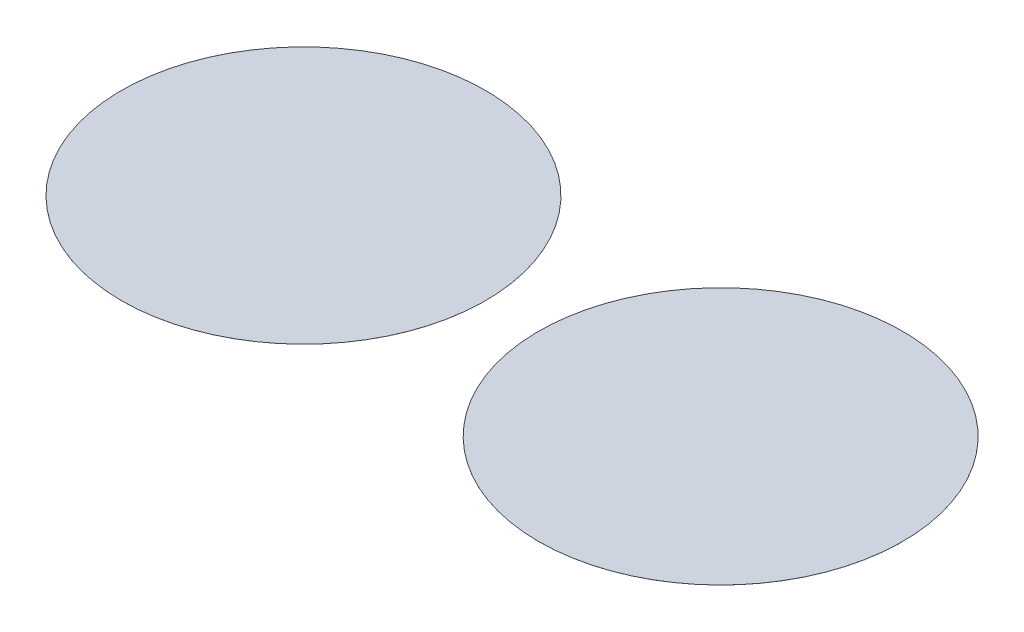
from build123d import *

# Parameters (mm, degrees)
SKETCH1_R             = 4500
BOSS_EXTRUDE1_DEPTH   = 0.5
BOSS_EXTRUDE1_2_DEPTH = 0.5


with BuildPart() as part:
    # Sketch1 → Boss-Extrude1 (new body)
    with BuildSketch(Plane(origin=(0, 0, 0), x_dir=(1, 0, 0), z_dir=(0, 1, 0))):
        with Locations(Location((-5155, 0, 0), (0, 0, 270))):  # turned: the seam where the file's is
            Circle(SKETCH1_R)
    extrude(amount=BOSS_EXTRUDE1_DEPTH)


with BuildPart() as body_2:
    # Sketch1 → Boss-Extrude1 2 (new body)
    with BuildSketch(Plane(origin=(0, 0, 0), x_dir=(1, 0, 0), z_dir=(0, 1, 0))):
        with Locations(Location((5155, 0, 0), (0, 0, 270))):  # turned: the seam where the file's is
            Circle(SKETCH1_R)
    extrude(amount=BOSS_EXTRUDE1_2_DEPTH)


solid = Compound([part.part, body_2.part])
